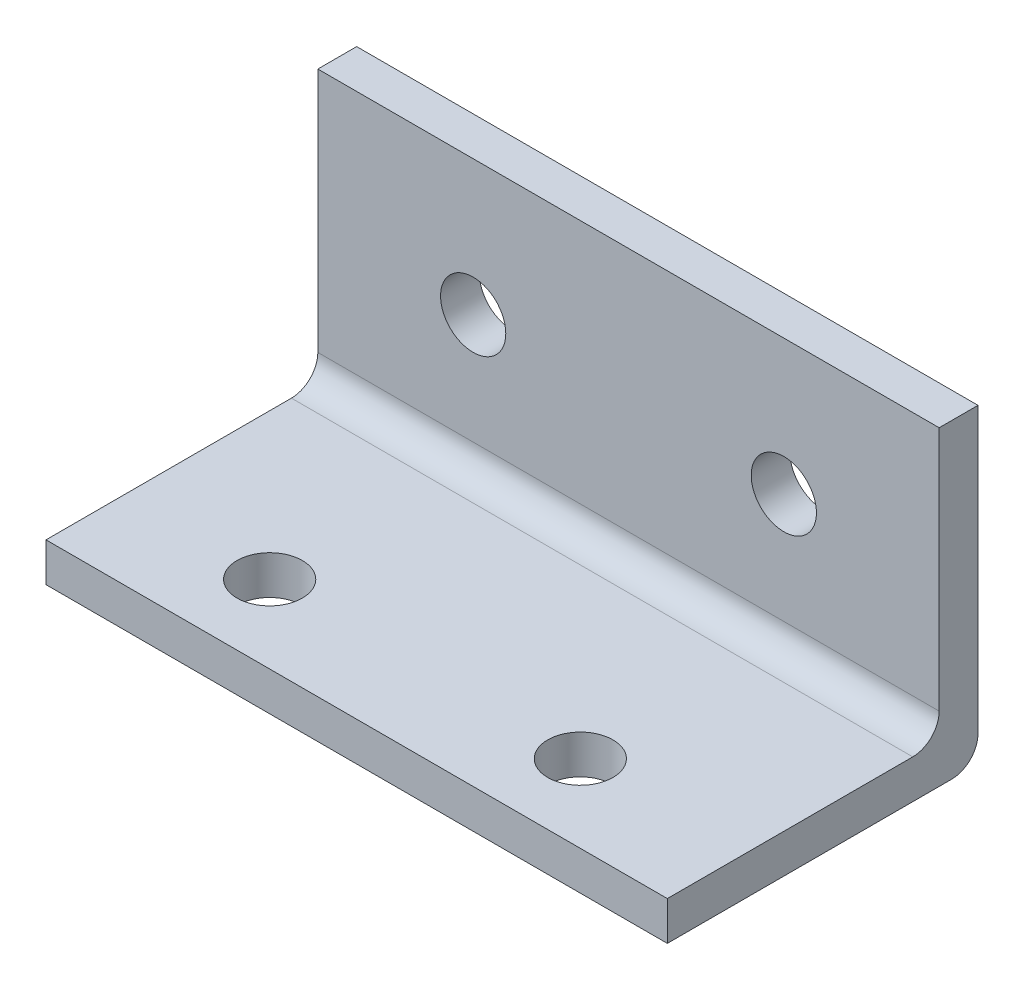
from build123d import *

# Parameters (mm, degrees)
BOSS_EXTRUDE1_DEPTH = 50.8
SKETCH2_R           = 2.667
CUT_EXTRUDE1_DEPTH  = 3.175
SKETCH3_R           = 2.667
CUT_EXTRUDE2_DEPTH  = 3.175
FILLET1_R           = 2.159


with BuildPart() as part:
    # Sketch1 → Boss-Extrude1 (new body)
    with BuildSketch(Plane(origin=(0, 0, 0), x_dir=(0, 0, -1), z_dir=(1, 0, 0))):
        Polygon((0, 0), (0, 25.4), (-3.175, 25.4), (-3.175, 3.175), (-25.4, 3.175), (-25.4, 0), align=None)
    extrude(amount=BOSS_EXTRUDE1_DEPTH)

    # Sketch2 → Cut-Extrude1 (cut)
    with BuildSketch(Plane(origin=(0, 3.175, 0), x_dir=(1, 0, 0), z_dir=(0, 1, 0))):
        with Locations((11.938, -19.05)):
            Circle(SKETCH2_R)
        with Locations((37.338, -19.05)):
            Circle(SKETCH2_R)
    extrude(amount=-CUT_EXTRUDE1_DEPTH, mode=Mode.SUBTRACT)

    # Sketch3 → Cut-Extrude2 (cut)
    with BuildSketch(Plane.XY.offset(3.175)):
        with Locations((38.1, 14.351)):
            Circle(SKETCH3_R)
        with Locations((12.7, 14.351)):
            Circle(SKETCH3_R)
    extrude(amount=-CUT_EXTRUDE2_DEPTH, mode=Mode.SUBTRACT)

    # Fillet1
    fillet1_edges = [part.edges().sort_by_distance(p)[0] for p in [
        (25.4, 3.175, 3.175),
        (25.4, 0, 0),
    ]]
    fillet(fillet1_edges, radius=FILLET1_R)


solid = part.part
